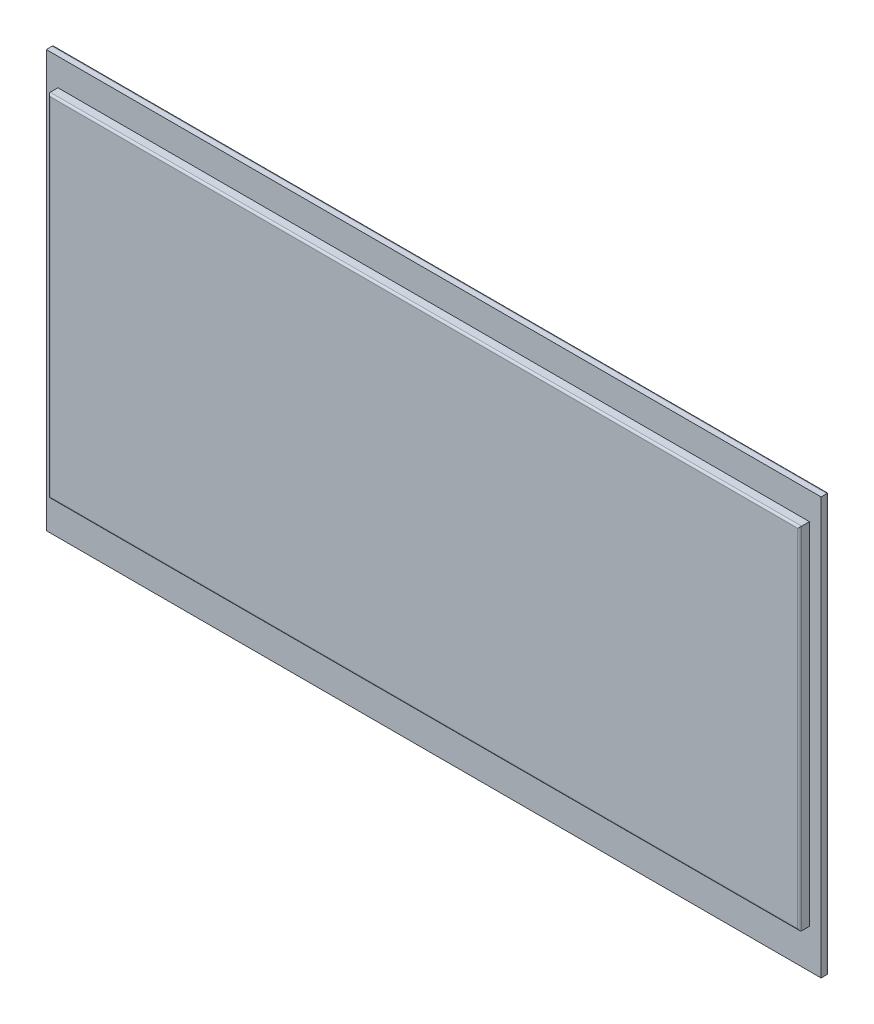
from build123d import *

# Parameters (mm, degrees)
SKETCH1_W           = 199
SKETCH1_H           = 107
BOSS_EXTRUDE1_DEPTH = 2
SKETCH2_W           = 193
SKETCH2_H           = 90
BOSS_EXTRUDE2_DEPTH = 2.5
FILLET2_R           = 0.5
FILLET3_R           = 0.5


with BuildPart() as part:
    # Sketch1 → Boss-Extrude1 (new body)
    with BuildSketch(Plane.XY):
        Rectangle(SKETCH1_W, SKETCH1_H)
    extrude(amount=BOSS_EXTRUDE1_DEPTH)

    # Sketch2 → Boss-Extrude2 (add)
    with BuildSketch(Plane.XY.offset(2)):
        with Locations((0, 1.5)):
            Rectangle(SKETCH2_W, SKETCH2_H)
    extrude(amount=BOSS_EXTRUDE2_DEPTH)

    # Fillet2
    fillet2_edges = [part.edges().sort_by_distance(p)[0] for p in [
        (-96.5, 1.5, 4.5),
        (0, -43.5, 4.5),
        (96.5, 1.5, 4.5),
        (0, 46.5, 4.5),
    ]]
    fillet(fillet2_edges, radius=FILLET2_R)

    # Fillet3
    fillet3_edges = [part.edges().sort_by_distance(p)[0] for p in [
        (0, -53.5, 0),
        (-99.5, 0, 0),
        (0, 53.5, 0),
        (99.5, 0, 0),
    ]]
    fillet(fillet3_edges, radius=FILLET3_R)


solid = part.part
